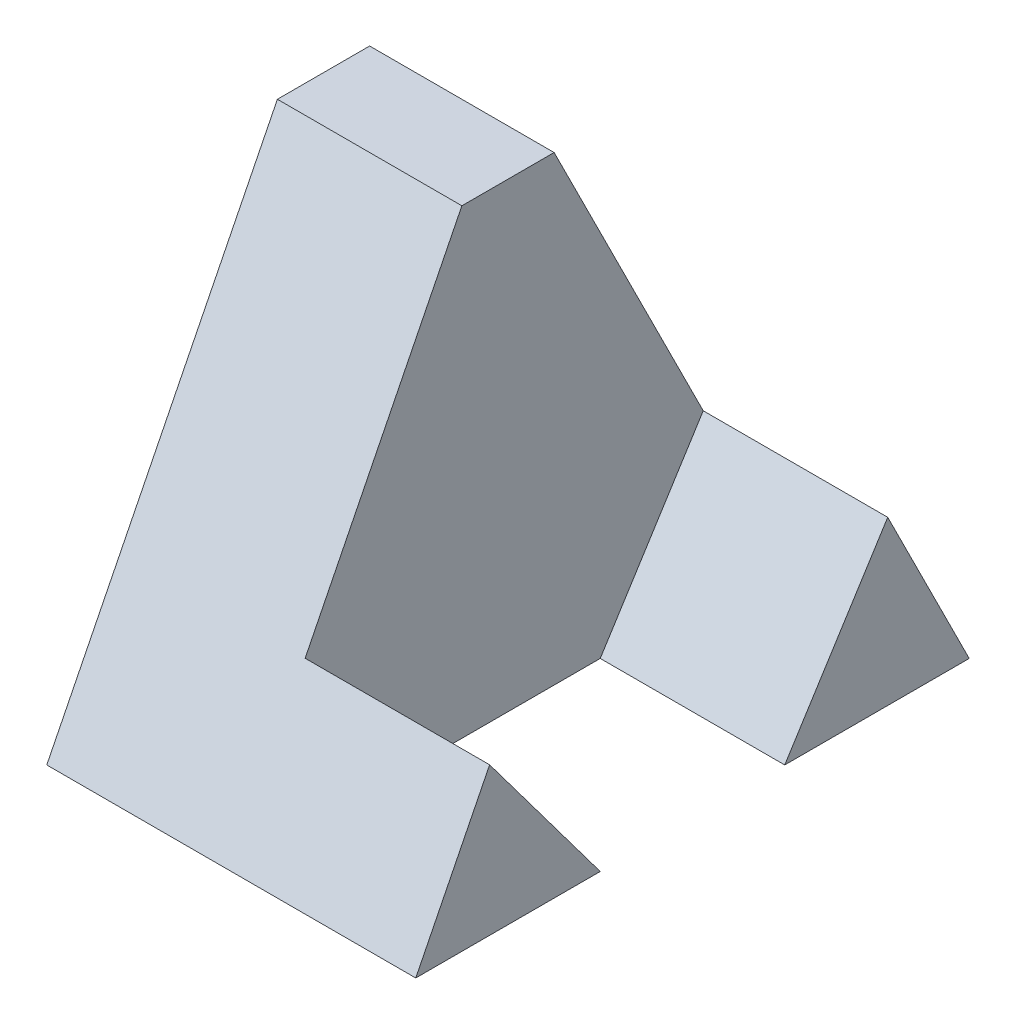
from build123d import *

# Parameters (mm, degrees)
BOSS_EXTRUDE1_DEPTH = 2
BOSS_EXTRUDE2_DEPTH = 2


with BuildPart() as part:
    # Sketch1 → Boss-Extrude1 (new body)
    with BuildSketch(Plane(origin=(0, 0, 0), x_dir=(0, 0, -1), z_dir=(1, 0, 0))):
        Polygon((0, 0), (2.5, 5), (3.5, 5), (6, 0), align=None)
    extrude(amount=BOSS_EXTRUDE1_DEPTH)

    # Sketch2 → Boss-Extrude2 (add)
    with BuildSketch(Plane(origin=(2, 0, 0), x_dir=(0, 0, -1), z_dir=(1, 0, 0))):
        Polygon((0, 0), (2, 0), (0.800710083, 1.601420167), align=None)
        Polygon((4, 0), (6, 0), (5.116370384, 1.767259231), align=None)
    extrude(amount=BOSS_EXTRUDE2_DEPTH)


solid = part.part
